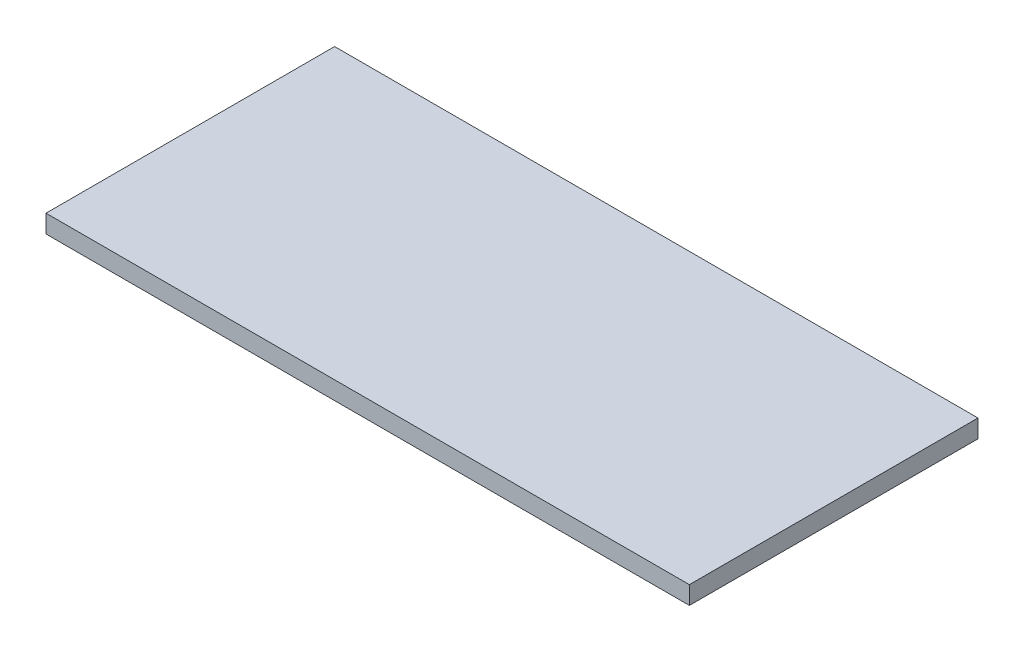
from build123d import *

# Parameters (mm, degrees)
SKETCH1_W           = 642
SKETCH1_H           = 288
BOSS_EXTRUDE1_DEPTH = 18


with BuildPart() as part:
    # Sketch1 → Boss-Extrude1 (new body)
    with BuildSketch(Plane(origin=(0, 0, 0), x_dir=(1, 0, 0), z_dir=(0, 1, 0))):
        Rectangle(SKETCH1_W, SKETCH1_H)
    extrude(amount=BOSS_EXTRUDE1_DEPTH)


solid = part.part
